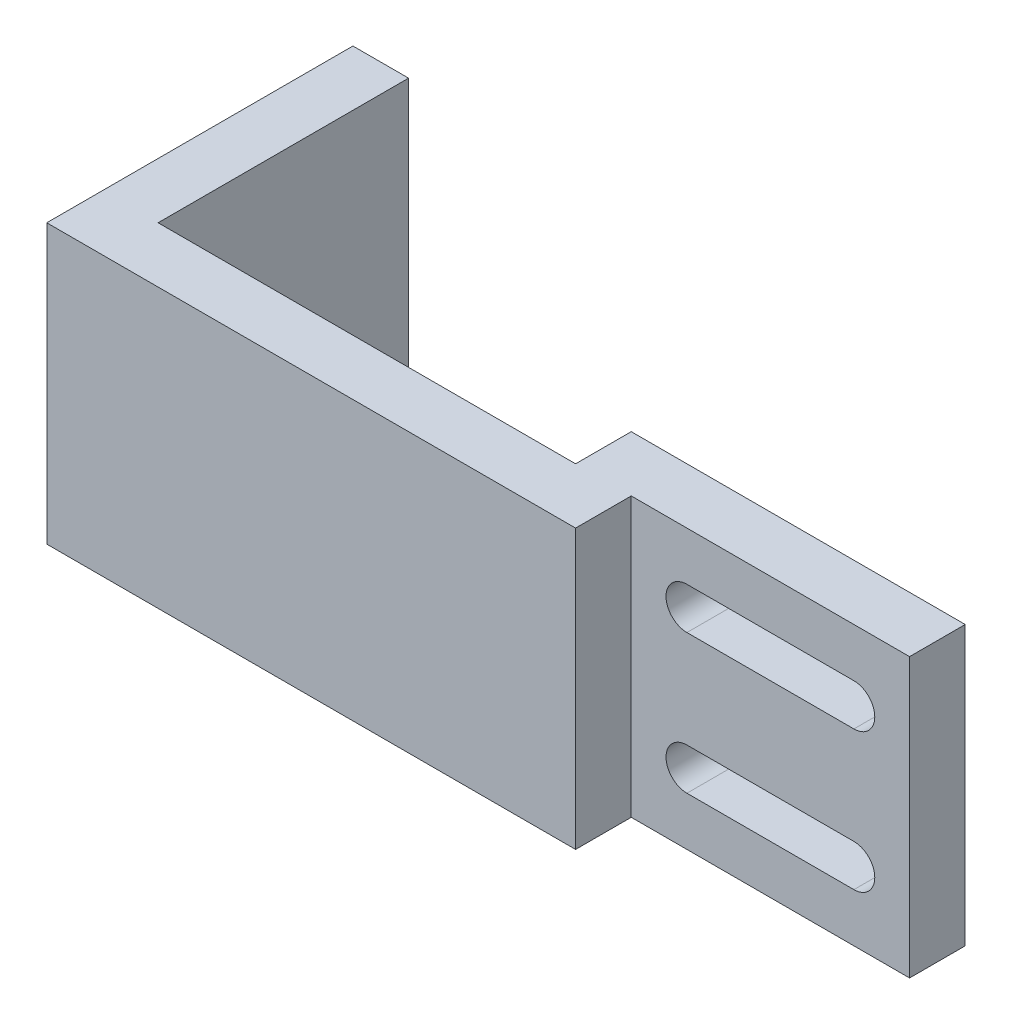
from build123d import *

# Parameters (mm, degrees)
SALIENTE_EXTRUIR1_DEPTH = 20
CORTAR_EXTRUIR1_DEPTH   = 20


with BuildPart() as part:
    # Croquis1 → Saliente-Extruir1 (new body)
    with BuildSketch(Plane(origin=(0, 0, 0), x_dir=(1, 0, 0), z_dir=(0, 1, 0))):
        Polygon((-19, 22), (-15, 22), (-15, 4), (15, 4), (15, 8), (39, 8), (39, 4), (19, 4), (19, 0), (-19, 0), align=None)
    extrude(amount=SALIENTE_EXTRUIR1_DEPTH)

    # Croquis2 → Cortar-Extruir1 (cut)
    with BuildSketch(Plane.XY.offset(-4)):
        with BuildLine():
            Line((35, 16.5), (23, 16.5))
            ThreePointArc((23, 16.5), (21.5, 15), (23, 13.5))
            Line((23, 13.5), (35, 13.5))
            ThreePointArc((35, 13.5), (36.5, 15), (35, 16.5))
        make_face()
        with BuildLine():
            Line((35, 3.5), (23, 3.5))
            ThreePointArc((23, 3.5), (21.5, 5), (23, 6.5))
            Line((23, 6.5), (35, 6.5))
            ThreePointArc((35, 6.5), (36.5, 5), (35, 3.5))
        make_face()
    extrude(amount=-CORTAR_EXTRUIR1_DEPTH, mode=Mode.SUBTRACT)


solid = part.part
